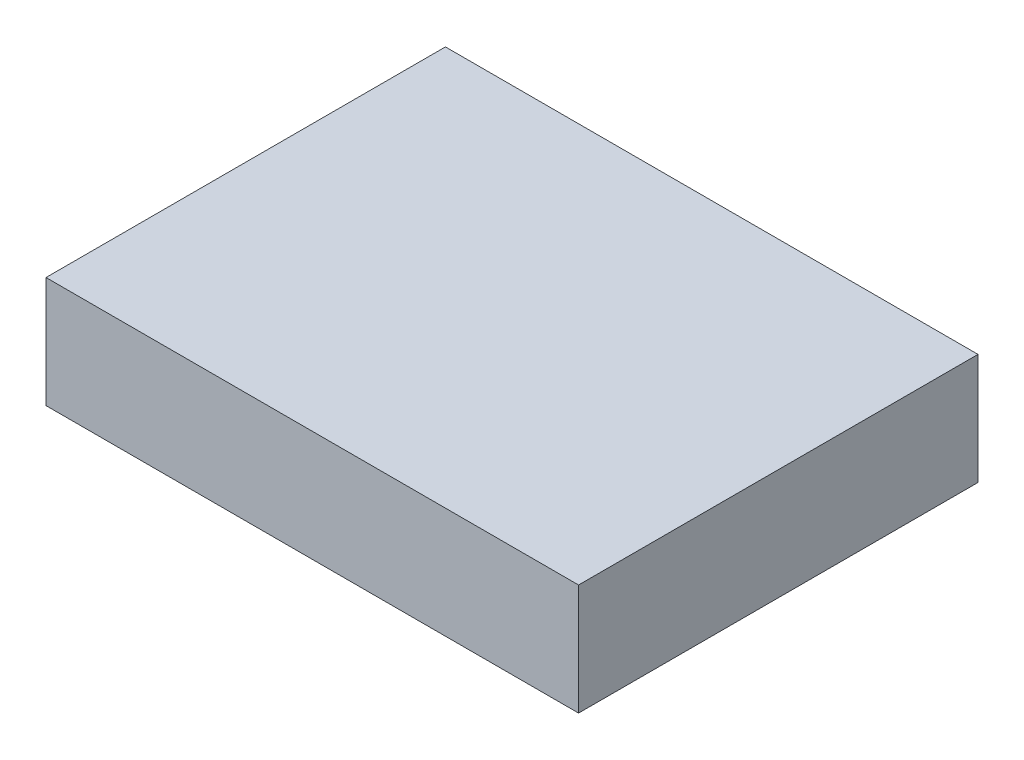
from build123d import *

# Parameters (mm, degrees)
SKETCH1_W           = 24
SKETCH1_H           = 18
BOSS_EXTRUDE1_DEPTH = 5


with BuildPart() as part:
    # Sketch1 → Boss-Extrude1 (new body)
    with BuildSketch(Plane(origin=(0, 0, 0), x_dir=(1, 0, 0), z_dir=(0, 1, 0))):
        Rectangle(SKETCH1_W, SKETCH1_H)
    extrude(amount=BOSS_EXTRUDE1_DEPTH)


solid = part.part
